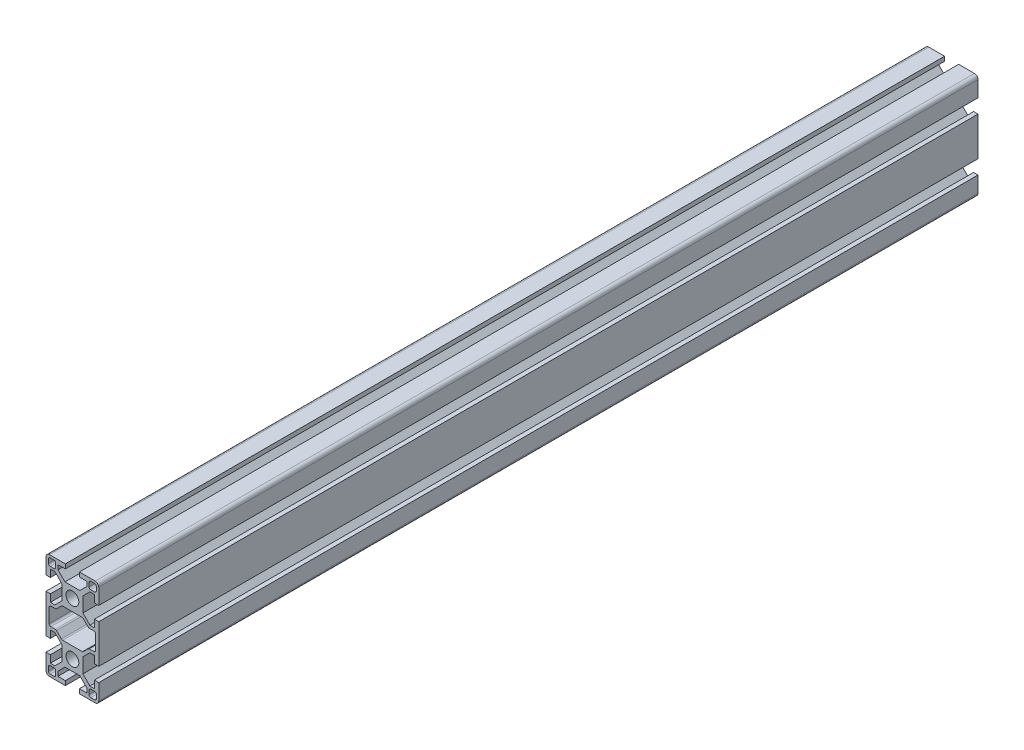
from build123d import *

# Parameters (mm, degrees)
SKETCH1_R           = 3.65
BOSS_EXTRUDE1_DEPTH = 500


with BuildPart() as part:
    # Sketch1 → Boss-Extrude1 (new body)
    with BuildSketch(Plane.XY):
        with BuildLine():
            Line((-15, -34), (-15, -43))
            ThreePointArc((-15, -43), (-14.414213562, -44.414213562), (-13, -45))
            Line((-13, -45), (-4, -45))
            Line((-4, -45), (-4, -42.5))
            Line((-4, -42.5), (-8.202216073, -42.5))
            Line((-8.202216073, -42.5), (-8.202216073, -39.955429293))
            Line((-8.202216073, -39.955429293), (-4.222649634, -35.975862854))
            Line((-4.222649634, -35.975862854), (4.222649634, -35.975862854))
            Line((4.222649634, -35.975862854), (8.202216073, -39.955429293))
            Line((8.202216073, -39.955429293), (8.202216073, -42.5))
            Line((8.202216073, -42.5), (4, -42.5))
            Line((4, -42.5), (4, -45))
            Line((4, -45), (13, -45))
            ThreePointArc((13, -45), (14.414213562, -44.414213562), (15, -43))
            Line((15, -43), (15, -34))
            Line((15, -34), (12.5, -34))
            Line((12.5, -34), (12.5, -38.202216073))
            Line((12.5, -38.202216073), (9.955429293, -38.202216073))
            Line((9.955429293, -38.202216073), (5.975862854, -34.222649634))
            Line((5.975862854, -34.222649634), (5.975862854, -25.777350366))
            Line((5.975862854, -25.777350366), (9.955429293, -21.797783927))
            Line((9.955429293, -21.797783927), (12.5, -21.797783927))
            Line((12.5, -21.797783927), (12.5, -26))
            Line((12.5, -26), (15, -26))
            Line((15, -26), (15, -4))
            Line((15, -4), (12.5, -4))
            Line((12.5, -4), (12.5, -8.202216073))
            Line((12.5, -8.202216073), (9.955429293, -8.202216073))
            Line((9.955429293, -8.202216073), (5.975862854, -4.222649634))
            Line((5.975862854, -4.222649634), (5.975862854, 4.222649634))
            Line((5.975862854, 4.222649634), (9.955429293, 8.202216073))
            Line((9.955429293, 8.202216073), (12.5, 8.202216073))
            Line((12.5, 8.202216073), (12.5, 4))
            Line((12.5, 4), (15, 4))
            Line((15, 4), (15, 13))
            ThreePointArc((15, 13), (14.414213562, 14.414213562), (13, 15))
            Line((13, 15), (4, 15))
            Line((4, 15), (4, 12.5))
            Line((4, 12.5), (8.202216073, 12.5))
            Line((8.202216073, 12.5), (8.202216073, 9.955429293))
            Line((8.202216073, 9.955429293), (4.222649634, 5.975862854))
            Line((4.222649634, 5.975862854), (-4.222649634, 5.975862854))
            Line((-4.222649634, 5.975862854), (-8.202216073, 9.955429293))
            Line((-8.202216073, 9.955429293), (-8.202216073, 12.5))
            Line((-8.202216073, 12.5), (-4, 12.5))
            Line((-4, 12.5), (-4, 15))
            Line((-4, 15), (-13, 15))
            ThreePointArc((-13, 15), (-14.414213562, 14.414213562), (-15, 13))
            Line((-15, 13), (-15, 4))
            Line((-15, 4), (-12.5, 4))
            Line((-12.5, 4), (-12.5, 8.202216073))
            Line((-12.5, 8.202216073), (-9.955429293, 8.202216073))
            Line((-9.955429293, 8.202216073), (-5.975862854, 4.222649634))
            Line((-5.975862854, 4.222649634), (-5.975862854, -4.222649634))
            Line((-5.975862854, -4.222649634), (-9.955429293, -8.202216073))
            Line((-9.955429293, -8.202216073), (-12.5, -8.202216073))
            Line((-12.5, -8.202216073), (-12.5, -4))
            Line((-12.5, -4), (-15, -4))
            Line((-15, -4), (-15, -26))
            Line((-15, -26), (-12.5, -26))
            Line((-12.5, -26), (-12.5, -21.797783927))
            Line((-12.5, -21.797783927), (-9.955429293, -21.797783927))
            Line((-9.955429293, -21.797783927), (-5.975862854, -25.777350366))
            Line((-5.975862854, -25.777350366), (-5.975862854, -34.222649634))
            Line((-5.975862854, -34.222649634), (-9.955429293, -38.202216073))
            Line((-9.955429293, -38.202216073), (-12.5, -38.202216073))
            Line((-12.5, -38.202216073), (-12.5, -34))
            Line((-12.5, -34), (-15, -34))
        make_face()
        with Locations((0, -30)):
            Circle(SKETCH1_R, mode=Mode.SUBTRACT)
        Circle(SKETCH1_R, mode=Mode.SUBTRACT)
        with BuildLine():
            Line((-10.463955813, -39.463955813), (-12.621642737, -39.463955813))
            ThreePointArc((-12.621642737, -39.463955813), (-13.328749519, -39.756849032), (-13.621642737, -40.463955813))
            Line((-13.621642737, -40.463955813), (-13.621642737, -42.621642737))
            ThreePointArc((-13.621642737, -42.621642737), (-13.328749519, -43.328749519), (-12.621642737, -43.621642737))
            Line((-12.621642737, -43.621642737), (-10.463955813, -43.621642737))
            ThreePointArc((-10.463955813, -43.621642737), (-9.756849032, -43.328749519), (-9.463955813, -42.621642737))
            Line((-9.463955813, -42.621642737), (-9.463955813, -40.463955813))
            ThreePointArc((-9.463955813, -40.463955813), (-9.756849032, -39.756849032), (-10.463955813, -39.463955813))
        make_face(mode=Mode.SUBTRACT)
        with BuildLine():
            Line((9.011119828, -9.620135349), (6.268756073, -6.877771595))
            ThreePointArc((6.268756073, -6.877771595), (5.944332724, -6.660998843), (5.561649292, -6.584878376))
            Line((5.561649292, -6.584878376), (-5.561649292, -6.584878376))
            ThreePointArc((-5.561649292, -6.584878376), (-5.944332724, -6.660998843), (-6.268756073, -6.877771595))
            Line((-6.268756073, -6.877771595), (-9.011119828, -9.620135349))
            ThreePointArc((-9.011119828, -9.620135349), (-9.335543176, -9.836908101), (-9.718226609, -9.913028568))
            Line((-9.718226609, -9.913028568), (-12.249589991, -9.913028568))
            ThreePointArc((-12.249589991, -9.913028568), (-12.956696772, -10.205921787), (-13.249589991, -10.913028568))
            Line((-13.249589991, -10.913028568), (-13.249589991, -19.086971432))
            ThreePointArc((-13.249589991, -19.086971432), (-12.956696772, -19.794078213), (-12.249589991, -20.086971432))
            Line((-12.249589991, -20.086971432), (-9.718226609, -20.086971432))
            ThreePointArc((-9.718226609, -20.086971432), (-9.335543176, -20.163091899), (-9.011119828, -20.379864651))
            Line((-9.011119828, -20.379864651), (-6.268756073, -23.122228405))
            ThreePointArc((-6.268756073, -23.122228405), (-5.944332724, -23.339001157), (-5.561649292, -23.415121624))
            Line((-5.561649292, -23.415121624), (5.561649292, -23.415121624))
            ThreePointArc((5.561649292, -23.415121624), (5.944332724, -23.339001157), (6.268756073, -23.122228405))
            Line((6.268756073, -23.122228405), (9.011119828, -20.379864651))
            ThreePointArc((9.011119828, -20.379864651), (9.335543176, -20.163091899), (9.718226609, -20.086971432))
            Line((9.718226609, -20.086971432), (12.249589991, -20.086971432))
            ThreePointArc((12.249589991, -20.086971432), (12.956696772, -19.794078213), (13.249589991, -19.086971432))
            Line((13.249589991, -19.086971432), (13.249589991, -10.913028568))
            ThreePointArc((13.249589991, -10.913028568), (12.956696772, -10.205921787), (12.249589991, -9.913028568))
            Line((12.249589991, -9.913028568), (9.718226609, -9.913028568))
            ThreePointArc((9.718226609, -9.913028568), (9.335543176, -9.836908101), (9.011119828, -9.620135349))
        make_face(mode=Mode.SUBTRACT)
        with BuildLine():
            Line((9.463955813, -40.463955813), (9.463955813, -42.621642737))
            ThreePointArc((9.463955813, -42.621642737), (9.756849032, -43.328749519), (10.463955813, -43.621642737))
            Line((10.463955813, -43.621642737), (12.621642737, -43.621642737))
            ThreePointArc((12.621642737, -43.621642737), (13.328749519, -43.328749519), (13.621642737, -42.621642737))
            Line((13.621642737, -42.621642737), (13.621642737, -40.463955813))
            ThreePointArc((13.621642737, -40.463955813), (13.328749519, -39.756849032), (12.621642737, -39.463955813))
            Line((12.621642737, -39.463955813), (10.463955813, -39.463955813))
            ThreePointArc((10.463955813, -39.463955813), (9.756849032, -39.756849032), (9.463955813, -40.463955813))
        make_face(mode=Mode.SUBTRACT)
        with BuildLine():
            Line((-9.463955813, 10.463955813), (-9.463955813, 12.621642737))
            ThreePointArc((-9.463955813, 12.621642737), (-9.756849032, 13.328749519), (-10.463955813, 13.621642737))
            Line((-10.463955813, 13.621642737), (-12.621642737, 13.621642737))
            ThreePointArc((-12.621642737, 13.621642737), (-13.328749519, 13.328749519), (-13.621642737, 12.621642737))
            Line((-13.621642737, 12.621642737), (-13.621642737, 10.463955813))
            ThreePointArc((-13.621642737, 10.463955813), (-13.328749519, 9.756849032), (-12.621642737, 9.463955813))
            Line((-12.621642737, 9.463955813), (-10.463955813, 9.463955813))
            ThreePointArc((-10.463955813, 9.463955813), (-9.756849032, 9.756849032), (-9.463955813, 10.463955813))
        make_face(mode=Mode.SUBTRACT)
        with BuildLine():
            Line((10.463955813, 9.463955813), (12.621642737, 9.463955813))
            ThreePointArc((12.621642737, 9.463955813), (13.328749519, 9.756849032), (13.621642737, 10.463955813))
            Line((13.621642737, 10.463955813), (13.621642737, 12.621642737))
            ThreePointArc((13.621642737, 12.621642737), (13.328749519, 13.328749519), (12.621642737, 13.621642737))
            Line((12.621642737, 13.621642737), (10.463955813, 13.621642737))
            ThreePointArc((10.463955813, 13.621642737), (9.756849032, 13.328749519), (9.463955813, 12.621642737))
            Line((9.463955813, 12.621642737), (9.463955813, 10.463955813))
            ThreePointArc((9.463955813, 10.463955813), (9.756849032, 9.756849032), (10.463955813, 9.463955813))
        make_face(mode=Mode.SUBTRACT)
    extrude(amount=BOSS_EXTRUDE1_DEPTH)


solid = part.part
